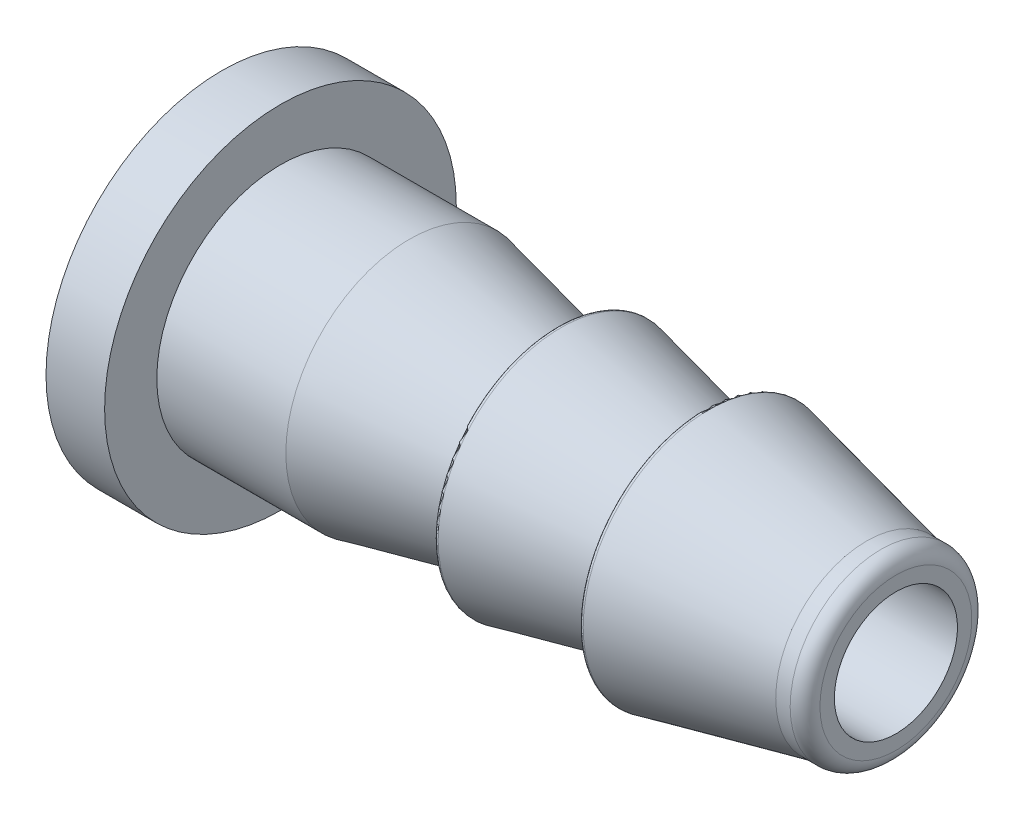
from build123d import *

# Parameters (mm, degrees)
SKETCH2_R           = 6
SKETCH2_R_2         = 2.1
BOSS_EXTRUDE1_DEPTH = 2
FILLET1_R           = 0.1
FILLET2_R           = 0.3


with BuildPart() as part:
    # Sketch1 → Revolve2 (revolve)
    with BuildSketch(Plane.XY, mode=Mode.PRIVATE) as revolve2_sk:
        with BuildLine():
            Line((0, 2.1), (8.384411392, 2.1))
            Line((8.384411392, 2.1), (21, 2.1))
            Line((21, 2.1), (21, 2.592))
            ThreePointArc((21, 2.592), (20.851210245, 2.951210245), (20.492, 3.1))
            Line((20.492, 3.1), (20, 3.1))
            Line((20, 3.1), (14.5, 4.319320645))
            Line((14.5, 4.319320645), (14.5, 3.1))
            Line((14.5, 3.1), (0, 3.1))
            Line((0, 3.1), (0, 2.1))
        make_face()
    revolve(revolve2_sk.sketch.rotate(Axis((0, 0, 0), (1, 0, 0)), 90), axis=Axis((0, 0, 0), (1, 0, 0)))

    # Sketch2 → Boss-Extrude1 (add)
    with BuildSketch(Plane.ZY):
        Circle(SKETCH2_R)
        Circle(SKETCH2_R_2, mode=Mode.SUBTRACT)
    extrude(amount=BOSS_EXTRUDE1_DEPTH)

    # Sketch3 → Revolve3 (revolve)
    with BuildSketch(Plane.XY, mode=Mode.PRIVATE) as revolve3_sk:
        Polygon((4.402141701, 4.219320645), (9.45107085, 3.1), (0, 3.1), (0, 4.219320645), align=None)
        Polygon((9.45107085, 4.219320645), (9.45107085, 3.1), (14.5, 3.1), align=None)
    revolve(revolve3_sk.sketch.rotate(Axis((-2, 0, 0), (1, 0, 0)), 90), axis=Axis((-2, 0, 0), (1, 0, 0)))

    # Fillet1
    fillet1_edges = [part.edges().sort_by_distance(p)[0] for p in [
        (9.45107085, 0, -4.219320645),
        (14.5, 0, -4.319320645),
    ]]
    fillet(fillet1_edges, radius=FILLET1_R)

    # Fillet2
    fillet2_edges = [part.edges().sort_by_distance(p)[0] for p in [
        (9.45107085, 0, -3.1),
        (14.5, 0, -3.1),
    ]]
    fillet(fillet2_edges, radius=FILLET2_R)


solid = part.part
